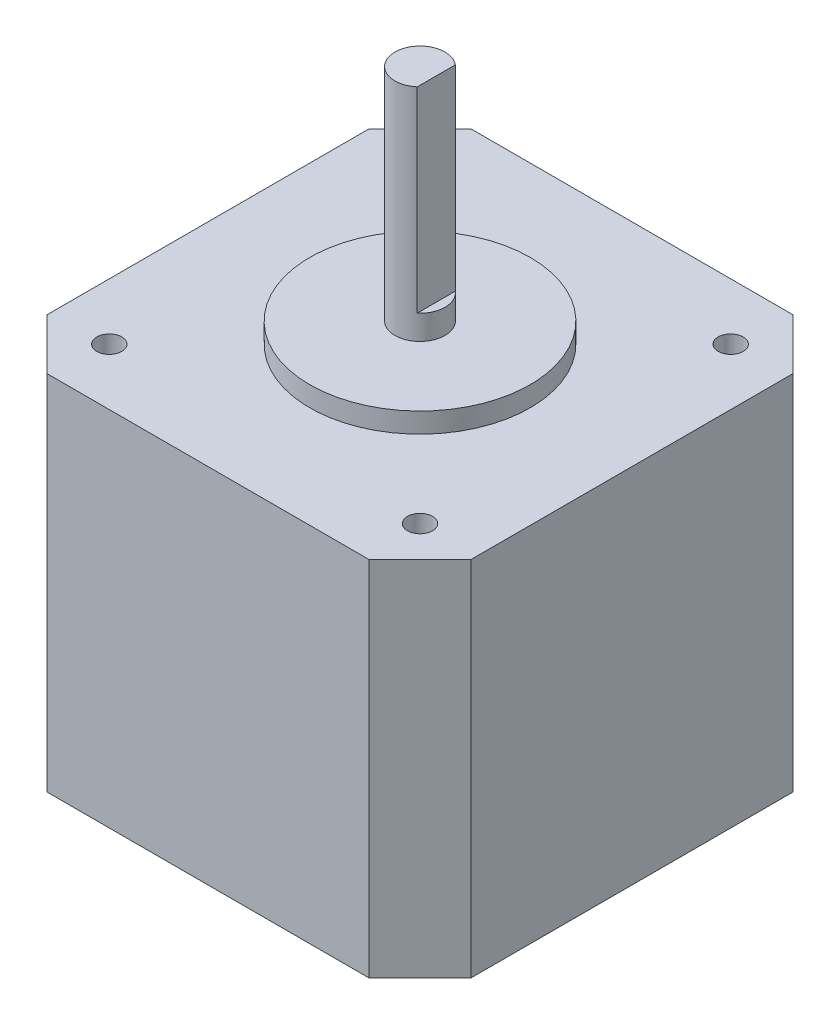
from build123d import *

# Parameters (mm, degrees)
BOSS_EXTRUDE1_DEPTH             = 36.158
TAP_DRILL_FOR_M3X0_5_TAP1_D     = 2.5
TAP_DRILL_FOR_M3X0_5_TAP1_DEPTH = 12.7
TAP_DRILL_FOR_M3X0_5_TAP1_TIP   = 0.751075774
SKETCH4_R                       = 11
BOSS_EXTRUDE2_DEPTH             = 2
SKETCH5_R                       = 2.5
BOSS_EXTRUDE3_DEPTH             = 22
CUT_EXTRUDE1_DEPTH              = 19.558


with BuildPart() as part:
    # Sketch1 → Boss-Extrude1 (new body)
    with BuildSketch(Plane(origin=(0, 0, 0), x_dir=(1, 0, 0), z_dir=(0, 1, 0))):
        Polygon((-21.15, 16.07), (-16.07, 21.15), (16.07, 21.15), (21.15, 16.07), (21.15, -16.07), (16.07, -21.15), (-16.07, -21.15), (-21.15, -16.07), align=None)
    extrude(amount=BOSS_EXTRUDE1_DEPTH)

    # Tap Drill for M3x0.5 Tap1
    with Locations(Plane(origin=(0, 36.158, 0), x_dir=(1, 0, 0), z_dir=(0, 1, 0))):
        with Locations((-15.5, 15.5), (15.5, 15.5), (15.5, -15.5), (-15.5, -15.5)):
            Hole(TAP_DRILL_FOR_M3X0_5_TAP1_D / 2, depth=TAP_DRILL_FOR_M3X0_5_TAP1_DEPTH)
            with Locations((0, 0, -(TAP_DRILL_FOR_M3X0_5_TAP1_DEPTH + TAP_DRILL_FOR_M3X0_5_TAP1_TIP / 2))):  # 118° drill point
                Cone(0, TAP_DRILL_FOR_M3X0_5_TAP1_D / 2, TAP_DRILL_FOR_M3X0_5_TAP1_TIP, mode=Mode.SUBTRACT)

    # Sketch4 → Boss-Extrude2 (add)
    with BuildSketch(Plane(origin=(0, 36.158, 0), x_dir=(1, 0, 0), z_dir=(0, 1, 0))):
        Circle(SKETCH4_R)
    extrude(amount=BOSS_EXTRUDE2_DEPTH)

    # Sketch5 → Boss-Extrude3 (add)
    with BuildSketch(Plane(origin=(0, 38.158, 0), x_dir=(1, 0, 0), z_dir=(0, 1, 0))):
        Circle(SKETCH5_R)
    extrude(amount=BOSS_EXTRUDE3_DEPTH)

    # Sketch6 → Cut-Extrude1 (cut)
    with BuildSketch(Plane(origin=(0, 60.158, 0), x_dir=(1, 0, 0), z_dir=(0, 1, 0))):
        with BuildLine():
            Line((1.623373896, 1.901225182), (1.623373896, -1.901225182))
            ThreePointArc((1.623373896, -1.901225182), (2.5, 0), (1.623373896, 1.901225182))
        make_face()
    extrude(amount=-CUT_EXTRUDE1_DEPTH, mode=Mode.SUBTRACT)


solid = part.part
